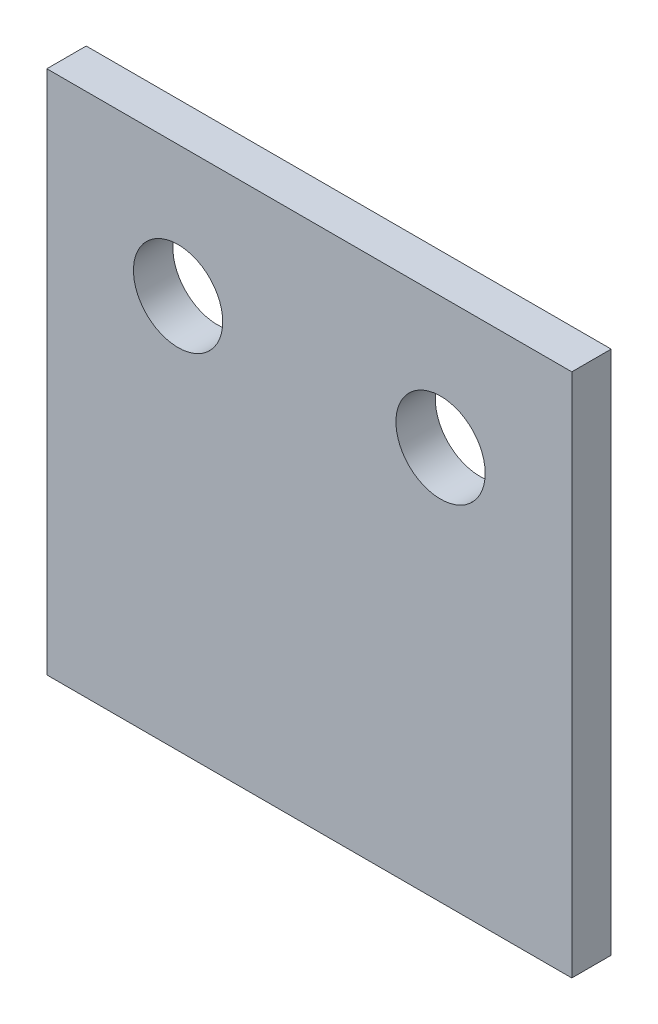
from build123d import *

# Parameters (mm, degrees)
ESQUISSE1_W        = 20
ESQUISSE1_H        = 20
BOSS_EXTRU_2_DEPTH = 1.5
D_GAGEMENT_M31_D   = 3.4


with BuildPart() as part:
    # Esquisse1 → Boss.-Extru.2 (new body)
    with BuildSketch(Plane.XY):
        with Locations((10, 10)):
            Rectangle(ESQUISSE1_W, ESQUISSE1_H)
    extrude(amount=BOSS_EXTRU_2_DEPTH)

    # Dégagement M31 (through all)
    with Locations(Plane(origin=(5, 15, 1.5), x_dir=(1, 0, 0), z_dir=(0, 0, 1))):
        with Locations((0, 0), (10, 0)):
            Hole(D_GAGEMENT_M31_D / 2)


solid = part.part
